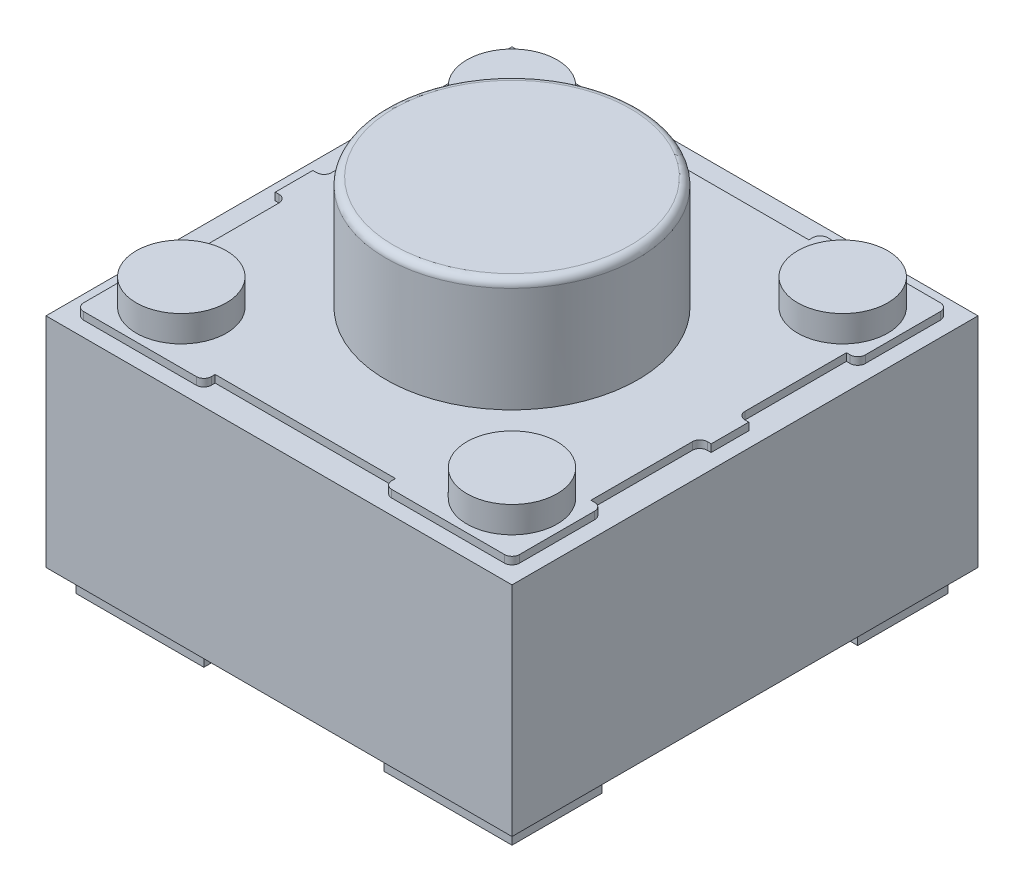
from build123d import *

# Parameters (mm, degrees)
ESQUISSE1_W             = 1.7
ESQUISSE1_H             = 1.2
BOSS_EXTRU_1_DEPTH      = 0.3
BOSS_EXTRU_1_2_DEPTH    = 0.3
BOSS_EXTRU_1_3_DEPTH    = 0.3
BOSS_EXTRU_1_4_DEPTH    = 0.3
ESQUISSE2_W             = 6.2
ESQUISSE2_H             = 6.2
BOSS_EXTRU_2_DEPTH      = 3
ESQUISSE3_W             = 6.2
ESQUISSE3_H             = 6.2
ENL_V_MAT_EXTRU_1_DEPTH = 0.1
ESQUISSE4_R             = 0.6
BOSS_EXTRU_3_DEPTH      = 0.35
ESQUISSE5_R             = 1.675
BOSS_EXTRU_4_DEPTH      = 1.5
CONG_1_R                = 0.1


with BuildPart() as part:
    # Esquisse1 → Boss.-Extru.1 (new body)
    with BuildSketch(Plane(origin=(0, 0, 0), x_dir=(1, 0, 0), z_dir=(0, 1, 0))):
        with Locations((1.05, 5.4)):
            Rectangle(ESQUISSE1_W, ESQUISSE1_H)
    extrude(amount=BOSS_EXTRU_1_DEPTH)



with BuildPart() as body_2:
    # Esquisse1 → Boss.-Extru.1 2 (new body)
    with BuildSketch(Plane(origin=(0, 0, 0), x_dir=(1, 0, 0), z_dir=(0, 1, 0))):
        with Locations((1.05, 0.8)):
            Rectangle(ESQUISSE1_W, ESQUISSE1_H)
    extrude(amount=BOSS_EXTRU_1_2_DEPTH)


with BuildPart() as body_3:
    # Esquisse1 → Boss.-Extru.1 3 (new body)
    with BuildSketch(Plane(origin=(0, 0, 0), x_dir=(1, 0, 0), z_dir=(0, 1, 0))):
        with Locations((5.15, 0.8)):
            Rectangle(ESQUISSE1_W, ESQUISSE1_H)
    extrude(amount=BOSS_EXTRU_1_3_DEPTH)


with BuildPart() as body_4:
    # Esquisse1 → Boss.-Extru.1 4 (new body)
    with BuildSketch(Plane(origin=(0, 0, 0), x_dir=(1, 0, 0), z_dir=(0, 1, 0))):
        with Locations((5.15, 5.4)):
            Rectangle(ESQUISSE1_W, ESQUISSE1_H)
    extrude(amount=BOSS_EXTRU_1_4_DEPTH)


with BuildPart() as part_1:
    add(part.part)

    add(body_2.part)  # Boss.-Extru.2 merges body 2

    add(body_3.part)  # Boss.-Extru.2 merges body 3

    add(body_4.part)  # Boss.-Extru.2 merges body 4
    # Esquisse2 → Boss.-Extru.2 (add)
    with BuildSketch(Plane(origin=(0, 0.3, 0), x_dir=(1, 0, 0), z_dir=(0, 1, 0))):
        with Locations((3.1, 3.1)):
            Rectangle(ESQUISSE2_W, ESQUISSE2_H)
    extrude(amount=BOSS_EXTRU_2_DEPTH)

    # Esquisse3 → Enlèv. mat.-Extru.1 (cut)
    with BuildSketch(Plane(origin=(0, 3.3, 0), x_dir=(1, 0, 0), z_dir=(0, 1, 0))):
        with Locations((3.1, 3.1)):
            Rectangle(ESQUISSE3_W, ESQUISSE3_H)
        with BuildLine():
            Line((0.3, 0.2), (1.8, 0.2))
            ThreePointArc((1.8, 0.2), (1.870710678, 0.229289322), (1.9, 0.3))
            Line((1.9, 0.3), (1.9, 0.35))
            Line((1.9, 0.35), (4.3, 0.35))
            Line((4.3, 0.35), (4.3, 0.3))
            ThreePointArc((4.3, 0.3), (4.329289322, 0.229289322), (4.4, 0.2))
            Line((4.4, 0.2), (5.9, 0.2))
            ThreePointArc((5.9, 0.2), (5.970710678, 0.229289322), (6, 0.3))
            Line((6, 0.3), (6, 1.3))
            ThreePointArc((6, 1.3), (5.970710678, 1.370710678), (5.9, 1.4))
            Line((5.9, 1.4), (5.85, 1.4))
            Line((5.85, 1.4), (5.85, 2.75))
            ThreePointArc((5.85, 2.75), (5.879289322, 2.820710678), (5.95, 2.85))
            Line((5.95, 2.85), (6, 2.85))
            Line((6, 2.85), (6, 3.35))
            Line((6, 3.35), (5.95, 3.35))
            ThreePointArc((5.95, 3.35), (5.879289322, 3.379289322), (5.85, 3.45))
            Line((5.85, 3.45), (5.85, 4.8))
            Line((5.85, 4.8), (5.9, 4.8))
            ThreePointArc((5.9, 4.8), (5.970710678, 4.829289322), (6, 4.9))
            Line((6, 4.9), (6, 5.9))
            ThreePointArc((6, 5.9), (5.970710678, 5.970710678), (5.9, 6))
            Line((5.9, 6), (4.4, 6))
            ThreePointArc((4.4, 6), (4.329289322, 5.970710678), (4.3, 5.9))
            Line((4.3, 5.9), (4.3, 5.85))
            Line((4.3, 5.85), (1.9, 5.85))
            Line((1.9, 5.85), (1.9, 5.9))
            ThreePointArc((1.9, 5.9), (1.870710678, 5.970710678), (1.8, 6))
            Line((1.8, 6), (0.3, 6))
            ThreePointArc((0.3, 6), (0.229289322, 5.970710678), (0.2, 5.9))
            Line((0.2, 5.9), (0.2, 4.9))
            ThreePointArc((0.2, 4.9), (0.229289322, 4.829289322), (0.3, 4.8))
            Line((0.3, 4.8), (0.35, 4.8))
            Line((0.35, 4.8), (0.35, 3.45))
            ThreePointArc((0.35, 3.45), (0.320710678, 3.379289322), (0.25, 3.35))
            Line((0.25, 3.35), (0.2, 3.35))
            Line((0.2, 3.35), (0.2, 2.85))
            Line((0.2, 2.85), (0.25, 2.85))
            ThreePointArc((0.25, 2.85), (0.320710678, 2.820710678), (0.35, 2.75))
            Line((0.35, 2.75), (0.35, 1.4))
            Line((0.35, 1.4), (0.3, 1.4))
            ThreePointArc((0.3, 1.4), (0.229289322, 1.370710678), (0.2, 1.3))
            Line((0.2, 1.3), (0.2, 0.3))
            ThreePointArc((0.2, 0.3), (0.229289322, 0.229289322), (0.3, 0.2))
        make_face(mode=Mode.SUBTRACT)
    extrude(amount=-ENL_V_MAT_EXTRU_1_DEPTH, mode=Mode.SUBTRACT)

    # Esquisse4 → Boss.-Extru.3 (add)
    with BuildSketch(Plane(origin=(0, 3.3, 0), x_dir=(1, 0, 0), z_dir=(0, 1, 0))):
        with Locations((0.9, 5.3)):
            Circle(ESQUISSE4_R)
        with Locations((5.3, 5.3)):
            Circle(ESQUISSE4_R)
        with Locations((0.9, 0.9)):
            Circle(ESQUISSE4_R)
        with Locations((5.3, 0.9)):
            Circle(ESQUISSE4_R)
    extrude(amount=BOSS_EXTRU_3_DEPTH)

    # Esquisse5 → Boss.-Extru.4 (add)
    with BuildSketch(Plane(origin=(0, 3.3, 0), x_dir=(1, 0, 0), z_dir=(0, 1, 0))):
        with Locations((3.1, 3.1)):
            Circle(ESQUISSE5_R)
    extrude(amount=BOSS_EXTRU_4_DEPTH)

    # Congé1
    cong_1_edges = [part_1.edges().sort_by_distance(p)[0] for p in [
        (1.425, 4.8, -3.1),
    ]]
    fillet(cong_1_edges, radius=CONG_1_R)


solid = part_1.part
